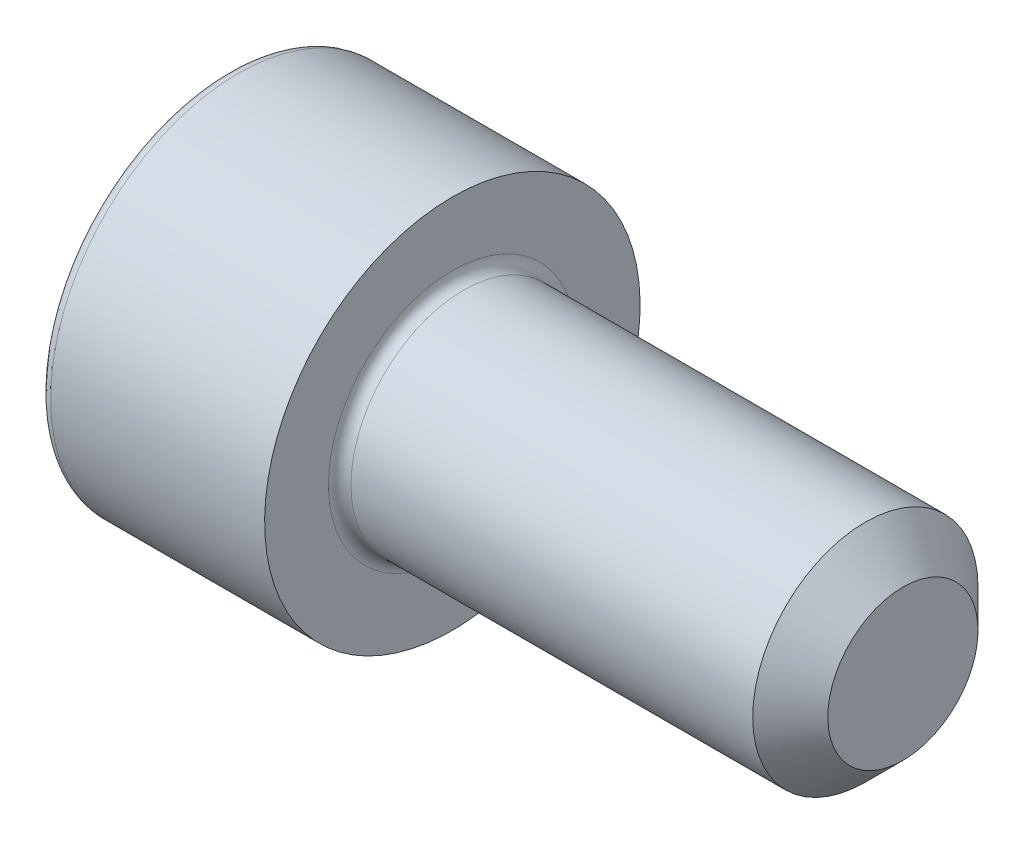
from build123d import *

# Parameters (mm, degrees)
CUT_EXTRUDE_1_DEPTH = 2.5
FILLET_1_R          = 0.3
CHAMFER_1_SIZE      = 1


with BuildPart() as part:
    # Эскиз1 → Повернуть1 (revolve)
    with BuildSketch(Plane.XY):
        Polygon((0, 0), (0, 5), (6, 5), (6, 3), (18, 3), (18, 0), align=None)
    revolve(axis=Axis((18, 0, 0), (-1, 0, 0)))

    # Эскиз2 → Вырез-Вытянуть1 (cut)
    with BuildSketch(Plane.ZY):
        Polygon((-1.443375673, 2.5), (-2.886751346, 0), (-1.443375673, -2.5), (1.443375673, -2.5), (2.886751346, 0), (1.443375673, 2.5), align=None)
    extrude(amount=-CUT_EXTRUDE_1_DEPTH, mode=Mode.SUBTRACT)

    # Скругление1
    fillet_1_edges = [part.edges().sort_by_distance(p)[0] for p in [
        (6, -3, 0),
        (0, -5, 0),
    ]]
    fillet(fillet_1_edges, radius=FILLET_1_R)

    # Фаска1
    chamfer_1_edges = [part.edges().sort_by_distance(p)[0] for p in [
        (18, -3, 0),
    ]]
    chamfer(chamfer_1_edges, length=CHAMFER_1_SIZE)


solid = part.part
